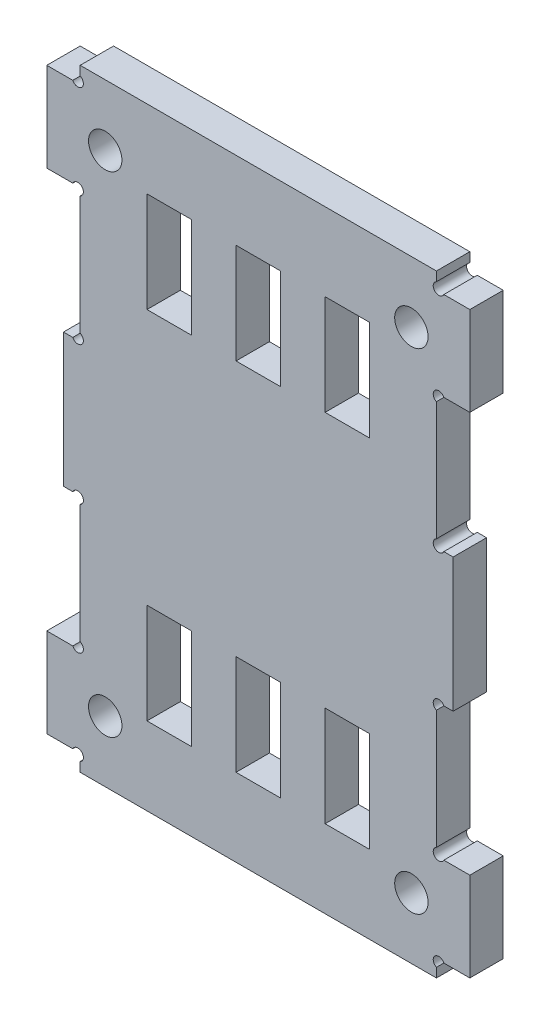
from build123d import *

# Parameters (mm, degrees)
SKETCH_1_W          = 38
SKETCH_1_H          = 55
EXTRUDE_1_DEPTH     = 3
SKETCH_2_W          = 3
SKETCH_2_H          = 36
SKETCH_2_H_2        = 1.5
CUT_EXTRUDE_1_DEPTH = 3
SKETCH_3_R          = 1.5
CUT_EXTRUDE_2_DEPTH = 4
SKETCH_4_W          = 4
SKETCH_4_H          = 9
CUT_EXTRUDE_3_DEPTH = 10
SKETCH_5_W          = 1.5
SKETCH_5_H          = 12
EXTRUDE_2_DEPTH     = 3
SKETCH_6_R          = 0.5
CUT_EXTRUDE_4_DEPTH = 10


with BuildPart() as part:
    # 草图1 → 凸台-拉伸1 (new body)
    with BuildSketch(Plane.XY):
        Rectangle(SKETCH_1_W, SKETCH_1_H)
    extrude(amount=EXTRUDE_1_DEPTH)

    # 草图2 → 切除-拉伸1 (cut)
    with BuildSketch(Plane.XY.offset(3)):
        with Locations((-17.5, 0)):
            Rectangle(SKETCH_2_W, SKETCH_2_H)
        with Locations((-17.5, 26.75)):
            Rectangle(SKETCH_2_W, SKETCH_2_H_2)
        with Locations((17.5, -26.75)):
            Rectangle(SKETCH_2_W, SKETCH_2_H_2)
        with Locations((17.5, 0)):
            Rectangle(SKETCH_2_W, SKETCH_2_H)
        with Locations((17.5, 26.75)):
            Rectangle(SKETCH_2_W, SKETCH_2_H_2)
        with Locations((-17.5, -26.75)):
            Rectangle(SKETCH_2_W, SKETCH_2_H_2)
    extrude(amount=-CUT_EXTRUDE_1_DEPTH, mode=Mode.SUBTRACT)

    # 草图3 → 切除-拉伸2 (cut, through all)
    with BuildSketch(Plane.XY.offset(3)):
        with Locations((-13.75, -22)):
            Circle(SKETCH_3_R)
        with Locations((13.75, -22)):
            Circle(SKETCH_3_R)
        with Locations((13.75, 22)):
            Circle(SKETCH_3_R)
        with Locations((-13.75, 22)):
            Circle(SKETCH_3_R)
    extrude(amount=-CUT_EXTRUDE_2_DEPTH, mode=Mode.SUBTRACT)

    # 草图4 → 切除-拉伸3 (cut)
    with BuildSketch(Plane.XY.offset(3)):
        with Locations((8, -16)):
            Rectangle(SKETCH_4_W, SKETCH_4_H)
        with Locations((0, -16)):
            Rectangle(SKETCH_4_W, SKETCH_4_H)
        with Locations((-8, -16)):
            Rectangle(SKETCH_4_W, SKETCH_4_H)
        with Locations((-8, 16)):
            Rectangle(SKETCH_4_W, SKETCH_4_H)
        with Locations((8, 16)):
            Rectangle(SKETCH_4_W, SKETCH_4_H)
        with Locations((0, 16)):
            Rectangle(SKETCH_4_W, SKETCH_4_H)
    extrude(amount=-CUT_EXTRUDE_3_DEPTH, mode=Mode.SUBTRACT)

    # 草图5 → 凸台-拉伸2 (add, through all)
    with BuildSketch(Plane.XY.offset(3)):
        with Locations((-16.75, 0)):
            Rectangle(SKETCH_5_W, SKETCH_5_H)
        with Locations((16.75, 0)):
            Rectangle(SKETCH_5_W, SKETCH_5_H)
    extrude(amount=-EXTRUDE_2_DEPTH)

    # 草图6 → 切除-拉伸4 (cut)
    with BuildSketch(Plane.XY.offset(3)):
        with Locations((-16.212132034, -26.212132034)):
            Circle(SKETCH_6_R)
        with Locations((-16.212132034, -17.787867966)):
            Circle(SKETCH_6_R)
        with Locations((-16.212132034, -6.212132034)):
            Circle(SKETCH_6_R)
        with Locations((16.212132034, -6.212132034)):
            Circle(SKETCH_6_R)
        with Locations((16.212132034, -17.787867966)):
            Circle(SKETCH_6_R)
        with Locations((16.212132034, -26.212132034)):
            Circle(SKETCH_6_R)
        with Locations((16.212132034, 26.212132034)):
            Circle(SKETCH_6_R)
        with Locations((16.212132034, 17.787867966)):
            Circle(SKETCH_6_R)
        with Locations((16.212132034, 6.212132034)):
            Circle(SKETCH_6_R)
        with Locations((-16.212132034, 6.212132034)):
            Circle(SKETCH_6_R)
        with Locations((-16.212132034, 17.787867966)):
            Circle(SKETCH_6_R)
        with Locations((-16.212132034, 26.212132034)):
            Circle(SKETCH_6_R)
    extrude(amount=-CUT_EXTRUDE_4_DEPTH, mode=Mode.SUBTRACT)


solid = part.part
